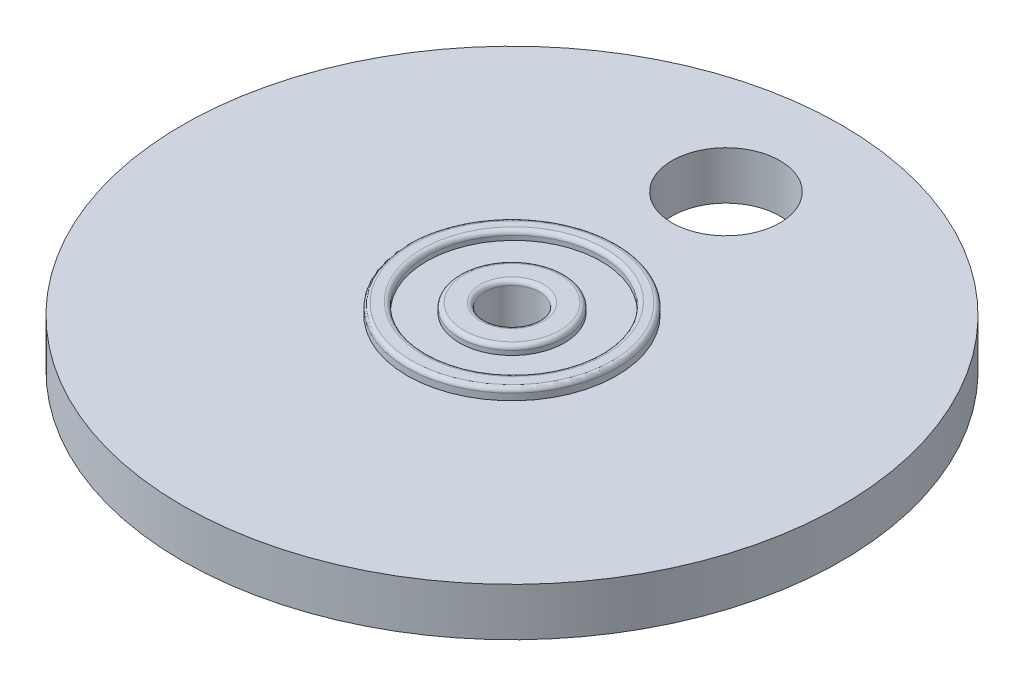
from build123d import *

# Parameters (mm, degrees)
CROQUIS1_R              = 12
CROQUIS1_R_2            = 3.125
SALIENTE_EXTRUIR1_DEPTH = 8
CROQUIS3_R              = 10
CROQUIS3_R_2            = 6
CORTAR_EXTRUIR1_DEPTH   = 1
CROQUIS4_R              = 10
CROQUIS4_R_2            = 6
CORTAR_EXTRUIR2_DEPTH   = 1
REDONDEO1_R             = 0.5
CROQUIS5_R              = 37.75
CROQUIS5_R_2            = 12
SALIENTE_EXTRUIR2_DEPTH = 2.75
CROQUIS6_R              = 6.182499901
CORTAR_EXTRUIR3_DEPTH   = 7.75


with BuildPart() as part:
    # Croquis1 → Saliente-Extruir1 (new body)
    with BuildSketch(Plane(origin=(0, 0, 0), x_dir=(1, 0, 0), z_dir=(0, 1, 0))):
        Circle(CROQUIS1_R)
        Circle(CROQUIS1_R_2, mode=Mode.SUBTRACT)
    extrude(amount=SALIENTE_EXTRUIR1_DEPTH)

    # Croquis3 → Cortar-Extruir1 (cut)
    with BuildSketch(Plane(origin=(0, 8, 0), x_dir=(1, 0, 0), z_dir=(0, 1, 0))):
        with Locations((0, 0.217552599)):
            Circle(CROQUIS3_R)
        Circle(CROQUIS3_R_2, mode=Mode.SUBTRACT)
    extrude(amount=-CORTAR_EXTRUIR1_DEPTH, mode=Mode.SUBTRACT)

    # Croquis4 → Cortar-Extruir2 (cut)
    with BuildSketch(Plane.XZ):
        with Locations((0, -0.217552599)):
            Circle(CROQUIS4_R)
        Circle(CROQUIS4_R_2, mode=Mode.SUBTRACT)
    extrude(amount=-CORTAR_EXTRUIR2_DEPTH, mode=Mode.SUBTRACT)

    # Redondeo1
    redondeo1_edges = [part.edges().sort_by_distance(p)[0] for p in [
        (-10, 8, -0.217552599),
        (-6, 8, 0),
        (-10, 0, -0.217552599),
        (-12, 0, 0),
        (-6, 0, 0),
        (-12, 8, 0),
        (-3.125, 0, 0),
        (-3.125, 8, 0),
    ]]
    fillet(redondeo1_edges, radius=REDONDEO1_R)

    # Croquis5 → Saliente-Extruir2 (add, symmetric)
    with BuildSketch(Plane(origin=(0, 4, 0), x_dir=(1, 0, 0), z_dir=(0, 1, 0))):
        Circle(CROQUIS5_R)
        Circle(CROQUIS5_R_2, mode=Mode.SUBTRACT)
    extrude(amount=SALIENTE_EXTRUIR2_DEPTH, both=True)

    # Croquis6 → Cortar-Extruir3 (cut, through all)
    with BuildSketch(Plane(origin=(0, 6.75, 0), x_dir=(1, 0, 0), z_dir=(0, 1, 0))):
        with Locations((0, 24.508276447)):
            Circle(CROQUIS6_R)
    extrude(amount=-CORTAR_EXTRUIR3_DEPTH, mode=Mode.SUBTRACT)


solid = part.part
